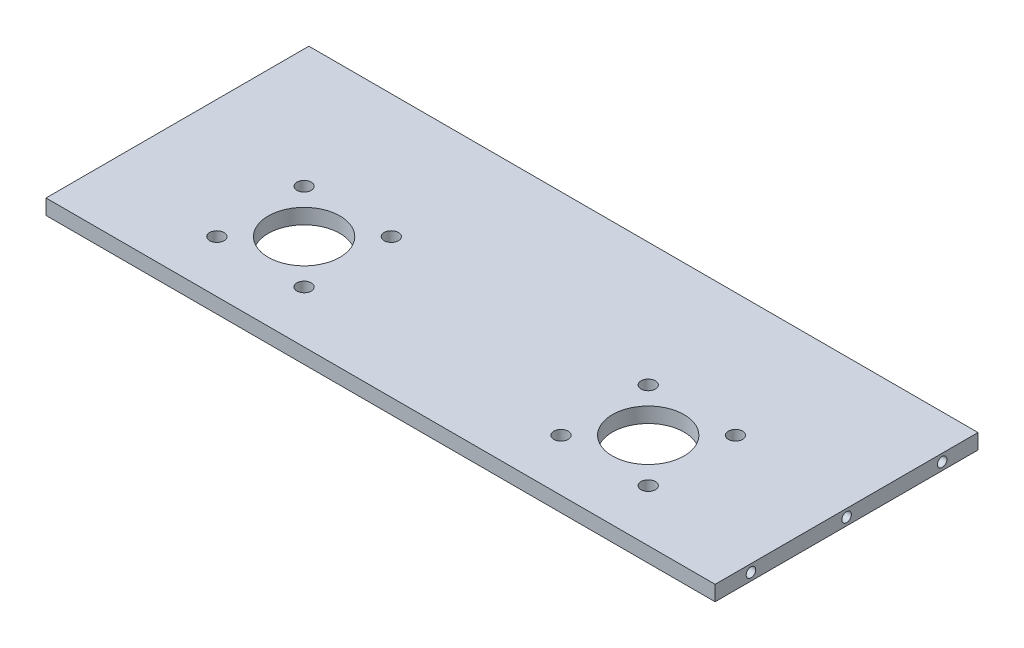
from build123d import *

# Parameters (mm, degrees)
CROQUIS1_W              = 280
CROQUIS1_H              = 110
SALIENTE_EXTRUIR1_DEPTH = 6.35
CROQUIS2_R              = 3
CROQUIS2_R_2            = 15
CORTAR_EXTRUIR2_DEPTH   = 20
CROQUIS5_R              = 2
CORTAR_EXTRUIR5_DEPTH   = 30
CROQUIS6_R              = 2
CORTAR_EXTRUIR6_DEPTH   = 30


with BuildPart() as part:
    # Croquis1 → Saliente-Extruir1 (new body)
    with BuildSketch(Plane(origin=(0, 0, 0), x_dir=(1, 0, 0), z_dir=(0, 1, 0))):
        with Locations((14.294294294, 1.756756757)):
            Rectangle(CROQUIS1_W, CROQUIS1_H)
    extrude(amount=SALIENTE_EXTRUIR1_DEPTH)

    # Croquis2 → Cortar-Extruir2 (cut)
    with BuildSketch(Plane(origin=(0, 0, 0), x_dir=(1, 0, 0), z_dir=(0, 1, 0))):
        with Locations((-39.455705706, 5.006756757)):
            Circle(CROQUIS2_R)
        with Locations((-75.955705706, 5.006756757)):
            Circle(CROQUIS2_R)
        with Locations((86.294294294, -13.243243243)):
            Circle(CROQUIS2_R_2)
        with Locations((-57.705705706, -13.243243243)):
            Circle(CROQUIS2_R_2)
        with Locations((-39.455705706, -31.493243243)):
            Circle(CROQUIS2_R)
        with Locations((-75.955705706, -31.493243243)):
            Circle(CROQUIS2_R)
        with Locations((104.544294294, 5.006756757)):
            Circle(CROQUIS2_R)
        with Locations((68.044294294, 5.006756757)):
            Circle(CROQUIS2_R)
        with Locations((104.544294294, -31.493243243)):
            Circle(CROQUIS2_R)
        with Locations((68.044294294, -31.493243243)):
            Circle(CROQUIS2_R)
    extrude(amount=CORTAR_EXTRUIR2_DEPTH, mode=Mode.SUBTRACT)

    # Croquis5 → Cortar-Extruir5 (cut)
    with BuildSketch(Plane.ZY.offset(125.705705706)):
        with Locations((38.243243243, 3.175)):
            Circle(CROQUIS5_R)
        with Locations((-41.756756757, 3.175)):
            Circle(CROQUIS5_R)
        with Locations((-1.756756757, 3.175)):
            Circle(CROQUIS5_R)
    extrude(amount=-CORTAR_EXTRUIR5_DEPTH, mode=Mode.SUBTRACT)

    # Croquis6 → Cortar-Extruir6 (cut)
    with BuildSketch(Plane(origin=(154.294294294, 0, 0), x_dir=(0, 0, -1), z_dir=(1, 0, 0))):
        with Locations((41.756756757, 3.175)):
            Circle(CROQUIS6_R)
        with Locations((-38.243243243, 3.175)):
            Circle(CROQUIS6_R)
        with Locations((1.756756757, 3.175)):
            Circle(CROQUIS6_R)
    extrude(amount=-CORTAR_EXTRUIR6_DEPTH, mode=Mode.SUBTRACT)


solid = part.part
